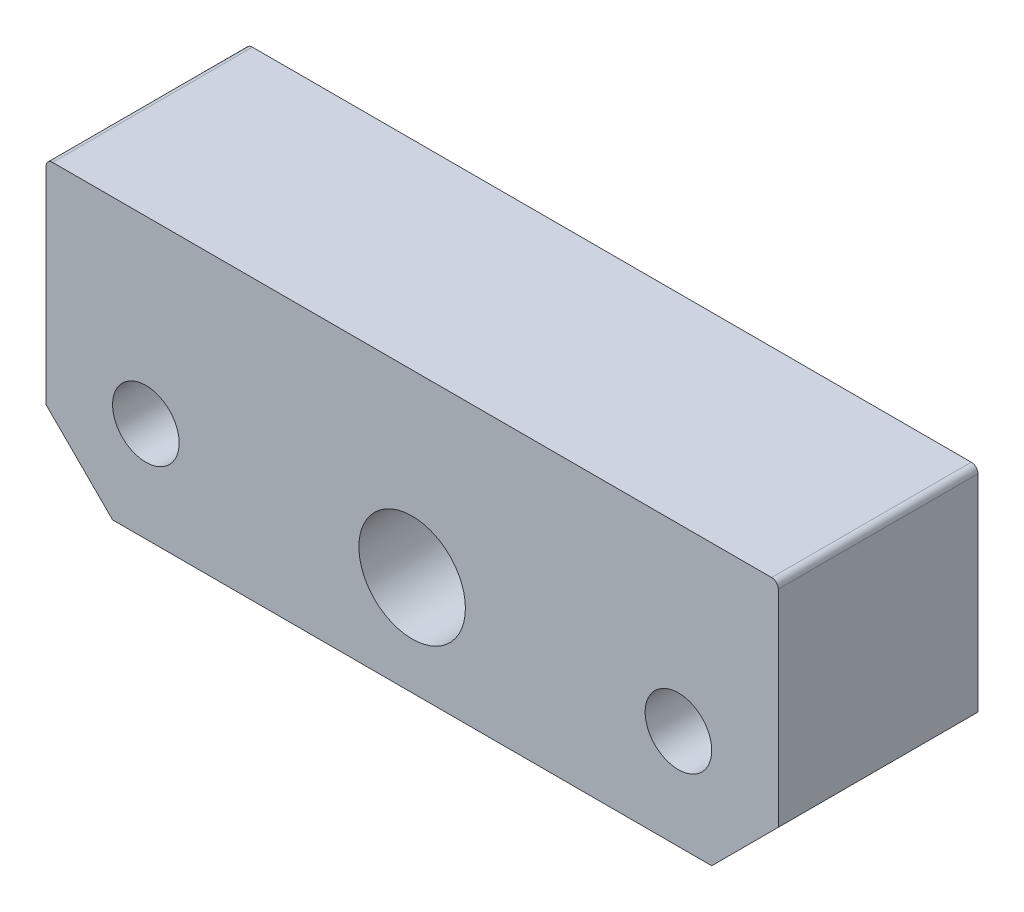
from build123d import *

# Parameters (mm, degrees)
CROQUIS1_W              = 110
CROQUIS1_H              = 42
SALIENTE_EXTRUIR1_DEPTH = 30
CHAFL_N1_SIZE           = 10
REDONDEO1_R             = 1
CROQUIS2_R              = 5
CROQUIS2_R_2            = 8
CORTAR_EXTRUIR1_DEPTH   = 30


with BuildPart() as part:
    # Croquis1 → Saliente-Extruir1 (new body)
    with BuildSketch(Plane.XY):
        Rectangle(CROQUIS1_W, CROQUIS1_H)
    extrude(amount=SALIENTE_EXTRUIR1_DEPTH)

    # Chaflán1
    chafl_n1_edges = [part.edges().sort_by_distance(p)[0] for p in [
        (55, -21, 15),
        (-55, -21, 15),
    ]]
    chamfer(chafl_n1_edges, length=CHAFL_N1_SIZE)

    # Redondeo1
    redondeo1_edges = [part.edges().sort_by_distance(p)[0] for p in [
        (-55, 21, 15),
        (55, 21, 15),
    ]]
    fillet(redondeo1_edges, radius=REDONDEO1_R)

    # Croquis2 → Cortar-Extruir1 (cut)
    with BuildSketch(Plane.XY.offset(30)):
        with Locations((-40, -6)):
            Circle(CROQUIS2_R)
        with Locations((40, -6)):
            Circle(CROQUIS2_R)
        with Locations((0, -6)):
            Circle(CROQUIS2_R_2)
    extrude(amount=-CORTAR_EXTRUIR1_DEPTH, mode=Mode.SUBTRACT)


solid = part.part
